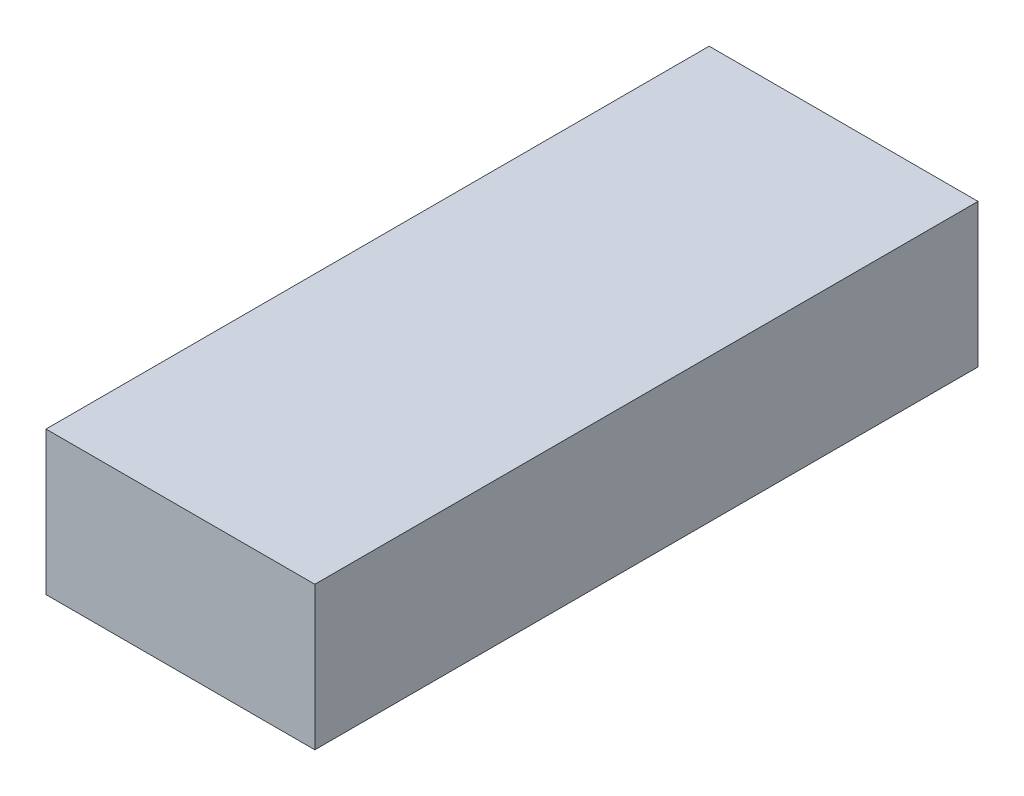
from build123d import *

# Parameters (mm, degrees)
SKETCH1_W           = 15
SKETCH1_H           = 37
BOSS_EXTRUDE1_DEPTH = 8


with BuildPart() as part:
    # Sketch1 → Boss-Extrude1 (new body)
    with BuildSketch(Plane(origin=(0, 0, 0), x_dir=(1, 0, 0), z_dir=(0, 1, 0))):
        with Locations((7.5, 18.5)):
            Rectangle(SKETCH1_W, SKETCH1_H)
    extrude(amount=BOSS_EXTRUDE1_DEPTH)


solid = part.part
